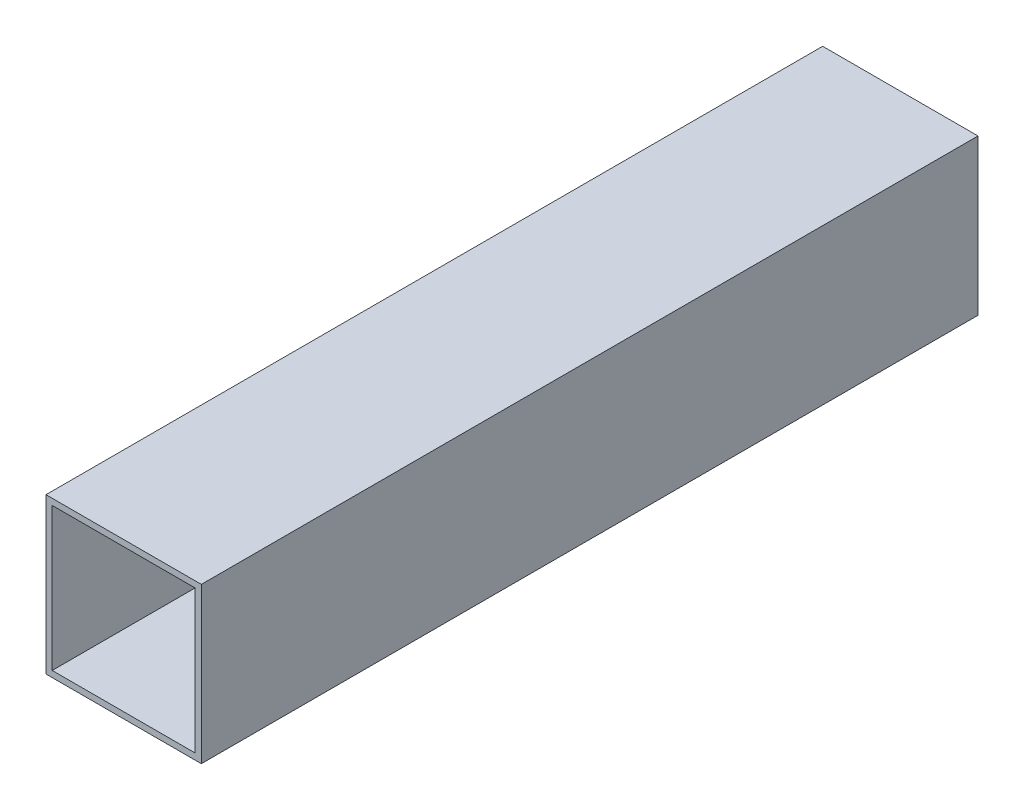
from build123d import *

# Parameters (mm, degrees)
ESBO_O1_W                = 40
ESBO_O1_H                = 40
ESBO_O1_W_2              = 36.8
ESBO_O1_H_2              = 36.8
RESSALTO_EXTRUS_O1_DEPTH = 200


with BuildPart() as part:
    # Esboço1 → Ressalto-extrusão1 (new body)
    with BuildSketch(Plane.XY):
        Rectangle(ESBO_O1_W, ESBO_O1_H)
        Rectangle(ESBO_O1_W_2, ESBO_O1_H_2, mode=Mode.SUBTRACT)
    extrude(amount=RESSALTO_EXTRUS_O1_DEPTH)


solid = part.part
